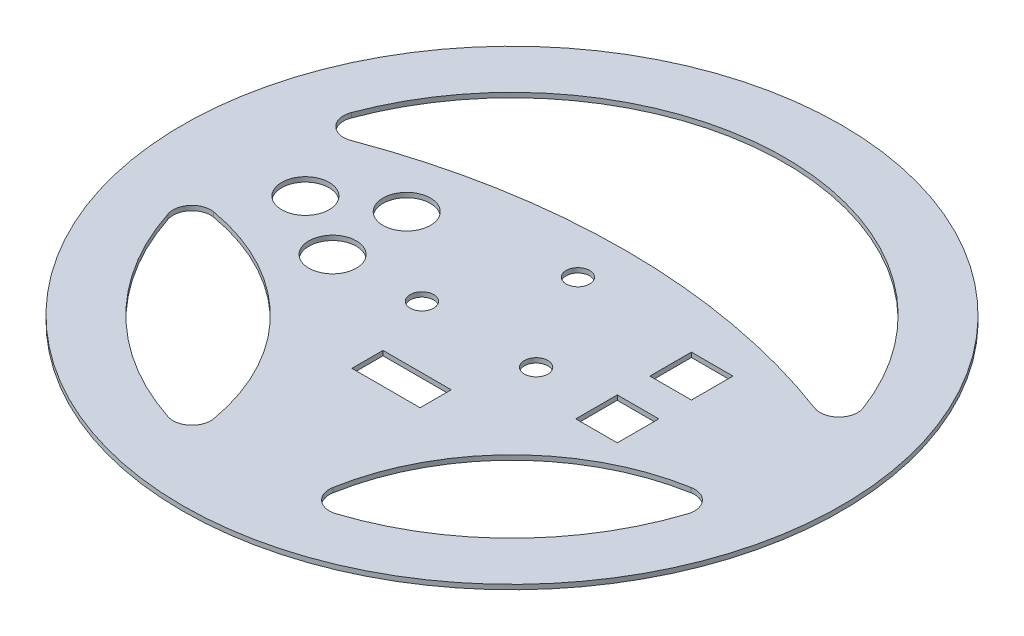
from build123d import *

# Parameters (mm, degrees)
SKETCH1_R           = 111.125
SKETCH1_R_2         = 3.96875
SKETCH1_R_3         = 8
SKETCH1_W           = 14
SKETCH1_H           = 14
SKETCH1_W_2         = 23
SKETCH1_H_2         = 10.5
BOSS_EXTRUDE1_DEPTH = 1.5875


with BuildPart() as part:
    # Sketch1 → Boss-Extrude1 (new body)
    with BuildSketch(Plane(origin=(0, 0, 0), x_dir=(1, 0, 0), z_dir=(0, 1, 0))):
        Circle(SKETCH1_R)
        with Locations((0, 22.225)):
            Circle(SKETCH1_R_2, mode=Mode.SUBTRACT)
        with Locations((19.247414599, -11.1125)):
            Circle(SKETCH1_R_2, mode=Mode.SUBTRACT)
        with Locations((-19.247414599, -11.1125)):
            Circle(SKETCH1_R_2, mode=Mode.SUBTRACT)
        with Locations((-48, -12.5)):
            Circle(SKETCH1_R_3, mode=Mode.SUBTRACT)
        with Locations((-69.650635095, 0)):
            Circle(SKETCH1_R_3, mode=Mode.SUBTRACT)
        with Locations((-48, 12.5)):
            Circle(SKETCH1_R_3, mode=Mode.SUBTRACT)
        with Locations((48, 12.5)):
            Rectangle(SKETCH1_W, SKETCH1_H, mode=Mode.SUBTRACT)
        with Locations((0, -37.246432928)):
            Rectangle(SKETCH1_W_2, SKETCH1_H_2, mode=Mode.SUBTRACT)
        with Locations((48, -12.5)):
            Rectangle(SKETCH1_W, SKETCH1_H, mode=Mode.SUBTRACT)
        with BuildLine():
            ThreePointArc((86.299834064, 32.095860566), (0, 92.075), (-86.299834064, 32.095860566))
            ThreePointArc((-86.299834064, 32.095860566), (-84.832280885, 25.386264259), (-78.118809332, 23.936541993))
            ThreePointArc((-78.118809332, 23.936541993), (0, 38.1), (78.118809332, 23.936541993))
            ThreePointArc((78.118809332, 23.936541993), (84.832280885, 25.386264259), (86.299834064, 32.095860566))
        make_face(mode=Mode.SUBTRACT)
        with BuildLine():
            ThreePointArc((-80.484779709, -20.088608264), (-40.736920582, -40.736920582), (-20.088608264, -80.484779709))
            ThreePointArc((-20.088608264, -80.484779709), (-22.177824514, -86.368987271), (-28.295419505, -87.619489042))
            ThreePointArc((-28.295419505, -87.619489042), (-65.106856878, -65.106856878), (-87.619489042, -28.295419505))
            ThreePointArc((-87.619489042, -28.295419505), (-86.368987271, -22.177824514), (-80.484779709, -20.088608264))
        make_face(mode=Mode.SUBTRACT)
        with BuildLine():
            ThreePointArc((20.088608264, -80.484779709), (40.736920582, -40.736920582), (80.484779709, -20.088608264))
            ThreePointArc((80.484779709, -20.088608264), (86.368987271, -22.177824514), (87.619489042, -28.295419505))
            ThreePointArc((87.619489042, -28.295419505), (65.106856878, -65.106856878), (28.295419505, -87.619489042))
            ThreePointArc((28.295419505, -87.619489042), (22.177824514, -86.368987271), (20.088608264, -80.484779709))
        make_face(mode=Mode.SUBTRACT)
    extrude(amount=BOSS_EXTRUDE1_DEPTH)


solid = part.part
